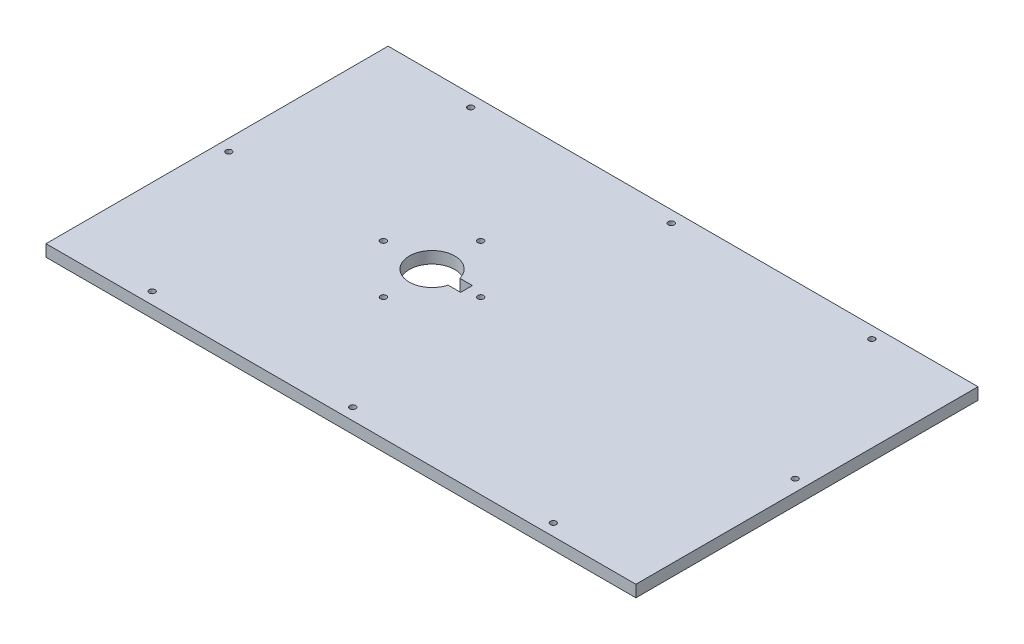
from build123d import *

# Parameters (mm, degrees)
SKETCH1_W           = 500
SKETCH1_H           = 290
SKETCH1_R           = 2.5
BOSS_EXTRUDE1_DEPTH = 10


with BuildPart() as part:
    # Sketch1 → Boss-Extrude1 (new body)
    with BuildSketch(Plane(origin=(0, 0, 0), x_dir=(1, 0, 0), z_dir=(0, 1, 0))):
        Rectangle(SKETCH1_W, SKETCH1_H)
        with Locations((-240, 0)):
            Circle(SKETCH1_R, mode=Mode.SUBTRACT)
        with Locations((-170, -135)):
            Circle(SKETCH1_R, mode=Mode.SUBTRACT)
        with Locations((-170, 135)):
            Circle(SKETCH1_R, mode=Mode.SUBTRACT)
        with Locations((170, 135)):
            Circle(SKETCH1_R, mode=Mode.SUBTRACT)
        with Locations((240, 0)):
            Circle(SKETCH1_R, mode=Mode.SUBTRACT)
        with Locations((170, -135)):
            Circle(SKETCH1_R, mode=Mode.SUBTRACT)
        with Locations((0, 135)):
            Circle(SKETCH1_R, mode=Mode.SUBTRACT)
        with Locations((0, -135)):
            Circle(SKETCH1_R, mode=Mode.SUBTRACT)
        with Locations((-26.530336654, 0)):
            Circle(SKETCH1_R, mode=Mode.SUBTRACT)
        with Locations((-67.780336654, -41.25)):
            Circle(SKETCH1_R, mode=Mode.SUBTRACT)
        with Locations((-109.030336654, 0)):
            Circle(SKETCH1_R, mode=Mode.SUBTRACT)
        with Locations((-67.780336654, 41.25)):
            Circle(SKETCH1_R, mode=Mode.SUBTRACT)
        with BuildLine():
            Line((-49.191025209, -5), (-38.530336654, -5))
            Line((-38.530336654, -5), (-38.530336654, 5))
            Line((-38.530336654, 5), (-49.191025209, 5))
            ThreePointArc((-49.191025209, 5), (-87.030336654, 0), (-49.191025209, -5))
        make_face(mode=Mode.SUBTRACT)
    extrude(amount=BOSS_EXTRUDE1_DEPTH)


solid = part.part
